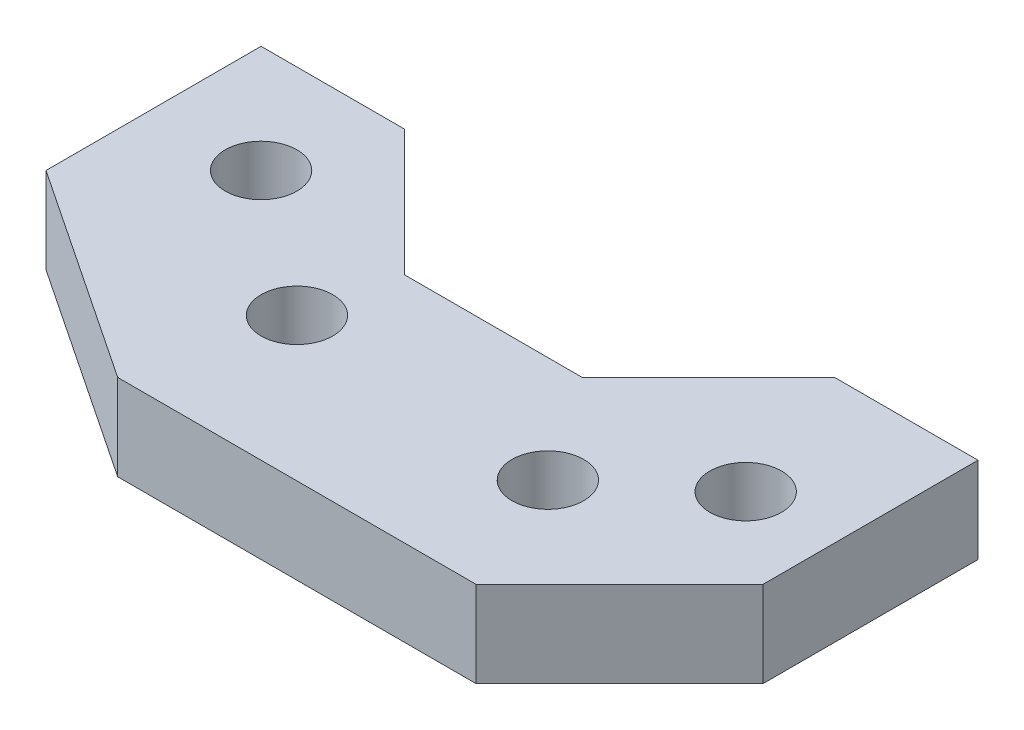
from build123d import *

# Parameters (mm, degrees)
SKETCH1_R           = 6.35
BOSS_EXTRUDE1_DEPTH = 15.24


with BuildPart() as part:
    # Sketch1 → Boss-Extrude1 (new body)
    with BuildSketch(Plane(origin=(0, 0, 0), x_dir=(1, 0, 0), z_dir=(0, 1, 0))):
        Polygon((79.248, -22.352), (101.6, 0), (127, 0), (127, -38.1), (101.6, -63.5), (38.1, -63.5), (0, -38.1), (0, 0), (25.4, 0), (47.752, -22.352), align=None)
        with Locations((19.05, -19.05)):
            Circle(SKETCH1_R, mode=Mode.SUBTRACT)
        with Locations((111.252, -25.4)):
            Circle(SKETCH1_R, mode=Mode.SUBTRACT)
        with Locations((44.45, -38.1)):
            Circle(SKETCH1_R, mode=Mode.SUBTRACT)
        with Locations((91.948, -41.148)):
            Circle(SKETCH1_R, mode=Mode.SUBTRACT)
    extrude(amount=BOSS_EXTRUDE1_DEPTH)


solid = part.part
